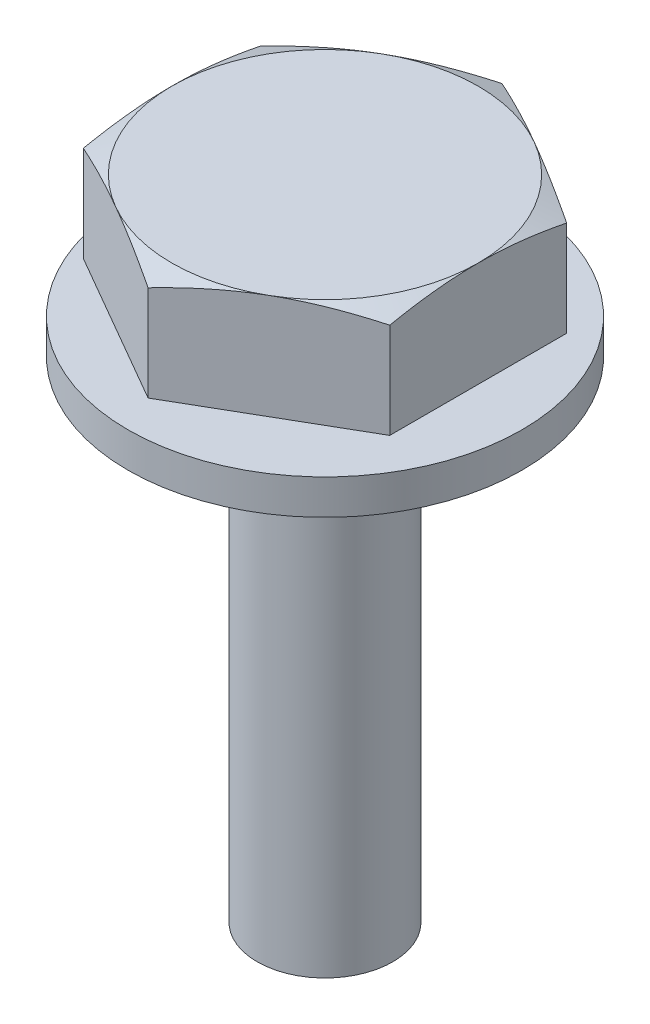
from build123d import *

# Parameters (mm, degrees)
KOPF_DEPTH = 2.8
SKIZZE3_W  = 1.091451884
SKIZZE3_H  = 0.4
SKIZZE2_W  = 1.55
SKIZZE2_H  = 12
SKIZZE4_W  = 2.35
SKIZZE4_H  = 0.8


with BuildPart() as part:
    # Skizze1 → Kopf (new body)
    with BuildSketch(Plane(origin=(0, 0.8, 0), x_dir=(1, 0, 0), z_dir=(0, 1, 0))):
        Polygon((3.5, 2.020725942), (0, 4.041451884), (-3.5, 2.020725942), (-3.5, -2.020725942), (0, -4.041451884), (3.5, -2.020725942), align=None)
    extrude(amount=KOPF_DEPTH)

    # Skizze3 → Schnitt Kopf (revolve, cut)
    with BuildSketch(Plane(origin=(0, 0, 0), x_dir=(0, 0, -1), z_dir=(1, 0, 0))):
        Polygon((4.041451884, 3.6), (3.5, 3.6), (4.041451884, 3.381239239), align=None)
        with Locations((3.495725942, 1)):
            Rectangle(SKIZZE3_W, SKIZZE3_H)
    revolve(axis=Axis((0, 0, 0), (0, 1, 0)), mode=Mode.SUBTRACT)

    # Skizze2 → Gewinde (revolve)
    with BuildSketch(Plane.XY, mode=Mode.PRIVATE) as gewinde_sk:
        with Locations((0.775, -5.2)):
            Rectangle(SKIZZE2_W, SKIZZE2_H)
    revolve(gewinde_sk.sketch.rotate(Axis((0, 5.086887038, 0), (0, -1, 0)), 270), axis=Axis((0, 5.086887038, 0), (0, -1, 0)))  # turned: the seam where the file's is

    # Skizze4 → Rotation1 (revolve)
    with BuildSketch(Plane(origin=(0, 0, 0), x_dir=(0, 0, -1), z_dir=(1, 0, 0))):
        with Locations((3.325, 0.4)):
            Rectangle(SKIZZE4_W, SKIZZE4_H)
    revolve(axis=Axis((0, 0, 0), (0, 1, 0)))


solid = part.part
